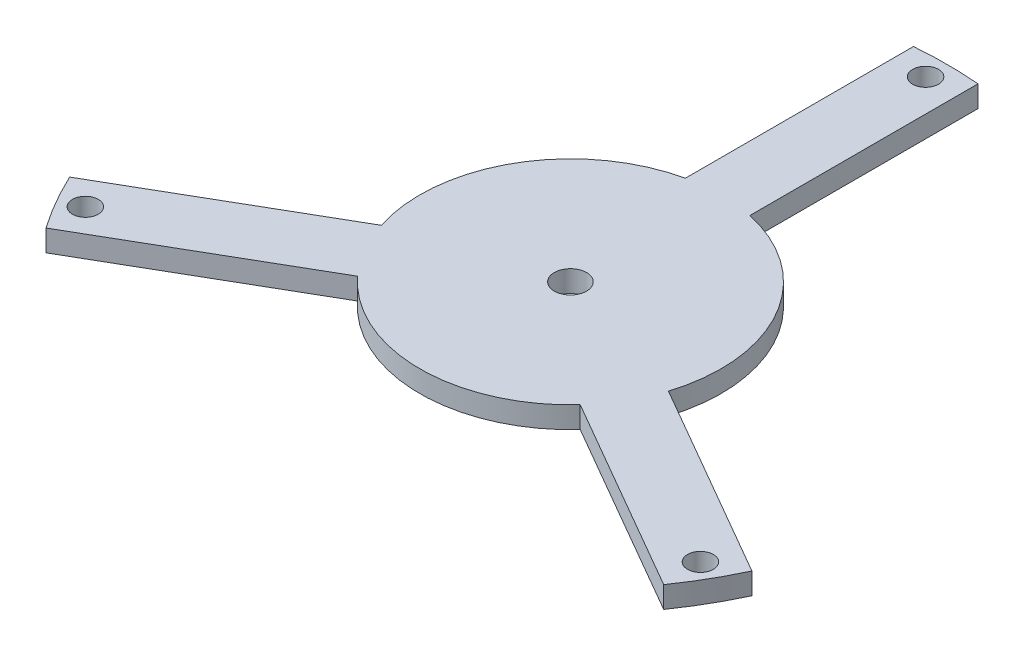
from build123d import *

# Parameters (mm, degrees)
SKETCH_1_R          = 6
EXTRUDE_1_DEPTH     = 10
SKETCH_2_R          = 7.5
CUT_EXTRUDE_1_DEPTH = 11


with BuildPart() as part:
    # 草图1 → 凸台-拉伸1 (new body)
    with BuildSketch(Plane(origin=(0, 0, 0), x_dir=(1, 0, 0), z_dir=(0, 1, 0))):
        with BuildLine():
            Line((158.496688705, -74.187597814), (66.713596412, -21.196604771))
            ThreePointArc((66.713596412, -21.196604771), (60.621778265, 35), (15, 68.373971656))
            Line((15, 68.373971656), (15, 174.355957742))
            ThreePointArc((15, 174.355957742), (0, 175), (-15, 174.355957742))
            Line((-15, 174.355957742), (-15, 68.373971656))
            ThreePointArc((-15, 68.373971656), (-60.621778265, 35), (-66.713596412, -21.196604771))
            Line((-66.713596412, -21.196604771), (-158.496688705, -74.187597814))
            ThreePointArc((-158.496688705, -74.187597814), (-151.554445662, -87.5), (-143.496688705, -100.168359928))
            Line((-143.496688705, -100.168359928), (-51.713596412, -47.177366885))
            ThreePointArc((-51.713596412, -47.177366885), (0, -70), (51.713596412, -47.177366885))
            Line((51.713596412, -47.177366885), (143.496688705, -100.168359928))
            ThreePointArc((143.496688705, -100.168359928), (151.554445662, -87.5), (158.496688705, -74.187597814))
        make_face()
        with Locations((0, 165)):
            Circle(SKETCH_1_R, mode=Mode.SUBTRACT)
        with Locations((142.894191624, -82.5)):
            Circle(SKETCH_1_R, mode=Mode.SUBTRACT)
        with Locations((-142.894191624, -82.5)):
            Circle(SKETCH_1_R, mode=Mode.SUBTRACT)
    extrude(amount=EXTRUDE_1_DEPTH)

    # 草图2 → 切除-拉伸1 (cut, through all)
    with BuildSketch(Plane(origin=(0, 10, 0), x_dir=(1, 0, 0), z_dir=(0, 1, 0))):
        Circle(SKETCH_2_R)
    extrude(amount=-CUT_EXTRUDE_1_DEPTH, mode=Mode.SUBTRACT)


solid = part.part
